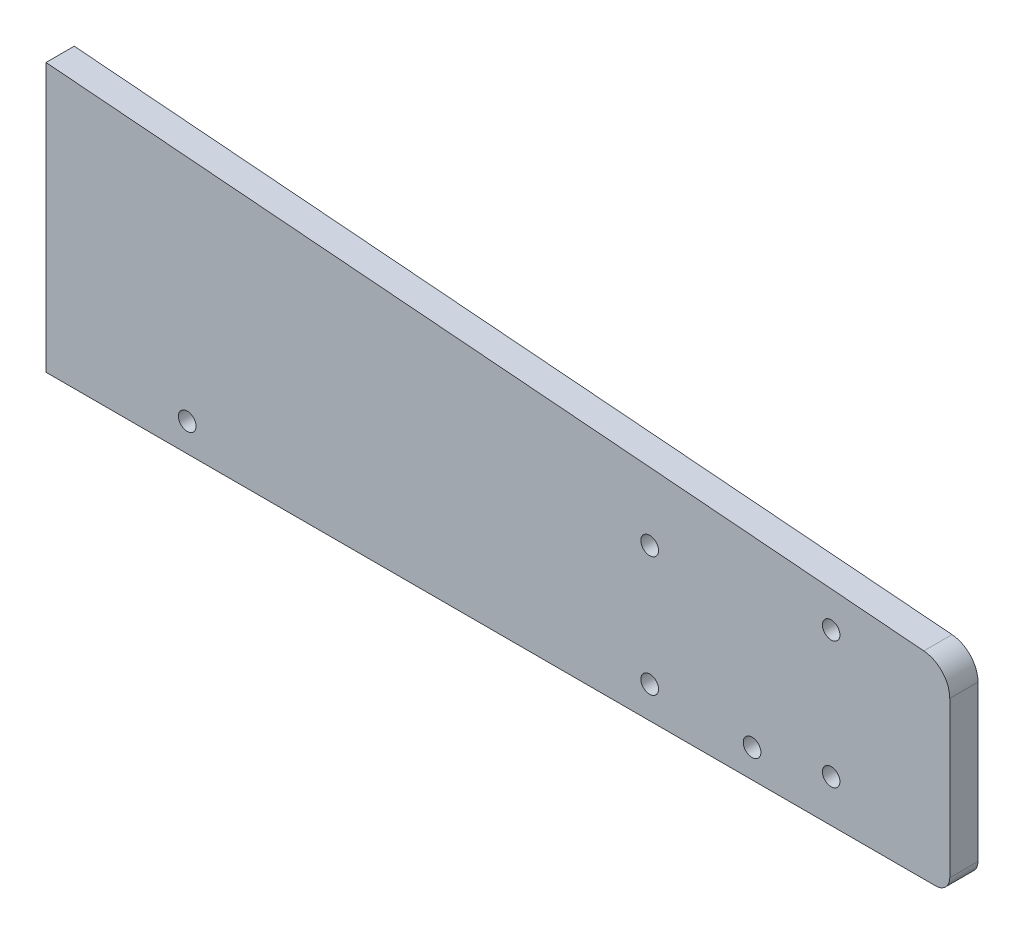
from build123d import *

# Parameters (mm, degrees)
BOSS_EXTRUDE1_DEPTH            = 12.7
SKETCH2_R                      = 3.96875
CUT_EXTRUDE1_DEPTH             = 13.7
FILLET1_R                      = 6.35
SKETCH4_R                      = 3.937
CUT_EXTRUDE2_DEPTH             = 13.7
F_5_16_0_3125_DIAMETER_HOLE1_D = 7.9375


with BuildPart() as part:
    # Sketch1 → Boss-Extrude1 (new body)
    with BuildSketch(Plane.XY):
        with BuildLine():
            Line((63.5, 0), (63.5, 120.65))
            Line((63.5, 120.65), (458.219565432, 88.85900811))
            ThreePointArc((458.219565432, 88.85900811), (466.533768826, 84.812244743), (469.9, 76.2))
            Line((469.9, 76.2), (469.9, 0))
            Line((469.9, 0), (63.5, 0))
        make_face()
    extrude(amount=BOSS_EXTRUDE1_DEPTH)

    # Sketch2 → Cut-Extrude1 (cut, through all)
    with BuildSketch(Plane.XY.offset(12.7)):
        with Locations((127, 12.7)):
            Circle(SKETCH2_R)
        with Locations((381, 12.7)):
            Circle(SKETCH2_R)
    extrude(amount=-CUT_EXTRUDE1_DEPTH, mode=Mode.SUBTRACT)

    # Fillet1
    fillet1_edges = [part.edges().sort_by_distance(p)[0] for p in [
        (469.9, 0, 6.35),
    ]]
    fillet(fillet1_edges, radius=FILLET1_R)

    # Sketch4 → Cut-Extrude2 (cut, through all)
    with BuildSketch(Plane(origin=(0, 0, 0), x_dir=(-1, 0, 0), z_dir=(0, 0, -1))):
        with Locations((-416.56762, 76.2)):
            Circle(SKETCH4_R)
        with Locations((-416.56762, 19.05)):
            Circle(SKETCH4_R)
    extrude(amount=-CUT_EXTRUDE2_DEPTH, mode=Mode.SUBTRACT)

    # 5/16 (0.3125) Diameter Hole1 (through all)
    with Locations(Plane.XY.offset(12.7)):
        with Locations((334.9625, 14.2875), (334.9625, 68.2625)):
            Hole(F_5_16_0_3125_DIAMETER_HOLE1_D / 2)


solid = part.part
